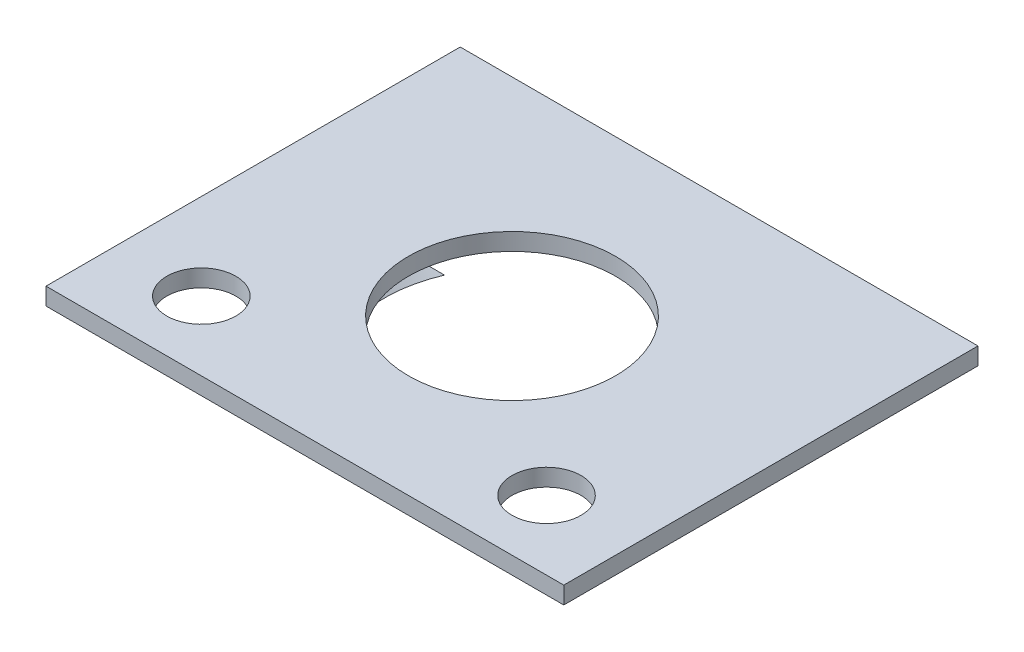
from build123d import *

# Parameters (mm, degrees)
SKETCH1_W                     = 38.1
SKETCH1_H                     = 30.48
SKETCH1_R                     = 7.62
SKETCH1_R_2                   = 2.54
BOSS_EXTRUDE1_DEPTH           = 1.27
BOSS_EXTRUDE2_DEPTH           = 1.524
BOSS_EXTRUDE3_DEPTH           = 0.762
BOSS_EXTRUDE3_DRAFT           = -45
BOSS_EXTRUDE3_PROFILE_2_DEPTH = 0.762
BOSS_EXTRUDE3_PROFILE_2_DRAFT = -45
BOSS_EXTRUDE3_PROFILE_3_DEPTH = 0.762
BOSS_EXTRUDE3_PROFILE_3_DRAFT = -45
SKETCH6_W                     = 5.08
SKETCH6_H                     = 1.016
BOSS_EXTRUDE4_DEPTH           = 0.254


with BuildPart() as part:
    # Sketch1 → Boss-Extrude1 (new body)
    with BuildSketch(Plane(origin=(0, 0, 0), x_dir=(1, 0, 0), z_dir=(0, 1, 0))):
        Rectangle(SKETCH1_W, SKETCH1_H)
        with Locations(Location((0, 0, 0), (0, 0, 270))):
            Circle(SKETCH1_R, mode=Mode.SUBTRACT)
        with Locations(Location((12.7, -10.16, 0), (0, 0, 270))):
            Circle(SKETCH1_R_2, mode=Mode.SUBTRACT)
        with Locations(Location((-12.7, -10.16, 0), (0, 0, 270))):
            Circle(SKETCH1_R_2, mode=Mode.SUBTRACT)
    extrude(amount=BOSS_EXTRUDE1_DEPTH)

    # Sketch2 → Boss-Extrude2 (add)
    with BuildSketch(Plane(origin=(0, 0, 0), x_dir=(-1, 0, 0), z_dir=(0, -1, 0))):
        with BuildLine():
            ThreePointArc((-9.731051279, 2.921), (-10.16, 0), (-9.731051279, -2.921))
            Line((-9.731051279, -2.921), (-12.271051279, -2.921))
            Line((-12.271051279, -2.921), (-12.271051279, 2.921))
            Line((-12.271051279, 2.921), (-9.731051279, 2.921))
        make_face()
        with BuildLine():
            ThreePointArc((-3.81, -9.418572079), (0, -10.16), (3.81, -9.418572079))
            Line((3.81, -9.418572079), (3.81, -11.958572079))
            Line((3.81, -11.958572079), (-3.81, -11.958572079))
            Line((-3.81, -11.958572079), (-3.81, -9.418572079))
        make_face()
        with BuildLine():
            ThreePointArc((9.731051279, -2.921), (10.16, 0), (9.731051279, 2.921))
            Line((9.731051279, 2.921), (12.271051279, 2.921))
            Line((12.271051279, 2.921), (12.271051279, -2.921))
            Line((12.271051279, -2.921), (9.731051279, -2.921))
        make_face()
    extrude(amount=BOSS_EXTRUDE2_DEPTH)


with BuildPart() as boss_extrude3_tool:
    # Sketch4 → Boss-Extrude3 (with draft: the straight prism first)
    with BuildSketch(Plane(origin=(0, -1.524, 0), x_dir=(-1, 0, 0), z_dir=(0, -1, 0))):
        with BuildLine():
            ThreePointArc((3.81, -9.418572079), (0, -10.16), (-3.81, -9.418572079))
            Line((-3.81, -9.418572079), (-3.81, -11.958572079))
            Line((-3.81, -11.958572079), (3.81, -11.958572079))
            Line((3.81, -11.958572079), (3.81, -9.418572079))
        make_face()
    extrude(amount=BOSS_EXTRUDE3_DEPTH)
    # Boss-Extrude3: the draft: its side faces are tilted about the plane it starts from
    boss_extrude3_sides = [boss_extrude3_tool.faces().sort_by_distance(p)[0] for p in [
        (3.81, -1.905, 10.688572079),
        (0, -1.905, 11.958572079),
        (-3.81, -1.905, 10.688572079),
        (0, -1.905, 10.16),
    ]]
    draft(boss_extrude3_sides, Plane(origin=(0, -1.524, 0), x_dir=(-1, 0, 0), z_dir=(0, -1, 0)), BOSS_EXTRUDE3_DRAFT)


with BuildPart() as part_1:
    add(part.part)

    # Boss-Extrude3: add boss_extrude3_tool
    add(boss_extrude3_tool.part)


with BuildPart() as boss_extrude3_profile_2_tool:
    # Sketch4 → Boss-Extrude3 profile 2 (with draft: the straight prism first)
    with BuildSketch(Plane(origin=(0, -1.524, 0), x_dir=(-1, 0, 0), z_dir=(0, -1, 0))):
        with BuildLine():
            Line((12.271051279, 2.921), (9.731051279, 2.921))
            ThreePointArc((9.731051279, 2.921), (10.16, 0), (9.731051279, -2.921))
            Line((9.731051279, -2.921), (12.271051279, -2.921))
            Line((12.271051279, -2.921), (12.271051279, 2.921))
        make_face()
    extrude(amount=BOSS_EXTRUDE3_PROFILE_2_DEPTH)
    # Boss-Extrude3 profile 2: the draft: its side faces are tilted about the plane it starts from
    boss_extrude3_profile_2_sides = [boss_extrude3_profile_2_tool.faces().sort_by_distance(p)[0] for p in [
        (-11.001051279, -1.905, -2.921),
        (-10.16, -1.905, 0),
        (-11.001051279, -1.905, 2.921),
        (-12.271051279, -1.905, 0),
    ]]
    draft(boss_extrude3_profile_2_sides, Plane(origin=(0, -1.524, 0), x_dir=(-1, 0, 0), z_dir=(0, -1, 0)), BOSS_EXTRUDE3_PROFILE_2_DRAFT)


with BuildPart() as part_2:
    add(part_1.part)

    # Boss-Extrude3 profile 2: add boss_extrude3_profile_2_tool
    add(boss_extrude3_profile_2_tool.part)


with BuildPart() as boss_extrude3_profile_3_tool:
    # Sketch4 → Boss-Extrude3 profile 3 (with draft: the straight prism first)
    with BuildSketch(Plane(origin=(0, -1.524, 0), x_dir=(-1, 0, 0), z_dir=(0, -1, 0))):
        with BuildLine():
            Line((-9.731051279, 2.921), (-12.271051279, 2.921))
            Line((-12.271051279, 2.921), (-12.271051279, -2.921))
            Line((-12.271051279, -2.921), (-9.731051279, -2.921))
            ThreePointArc((-9.731051279, -2.921), (-10.16, 0), (-9.731051279, 2.921))
        make_face()
    extrude(amount=BOSS_EXTRUDE3_PROFILE_3_DEPTH)
    # Boss-Extrude3 profile 3: the draft: its side faces are tilted about the plane it starts from
    boss_extrude3_profile_3_sides = [boss_extrude3_profile_3_tool.faces().sort_by_distance(p)[0] for p in [
        (11.001051279, -1.905, -2.921),
        (12.271051279, -1.905, 0),
        (11.001051279, -1.905, 2.921),
        (10.16, -1.905, 0),
    ]]
    draft(boss_extrude3_profile_3_sides, Plane(origin=(0, -1.524, 0), x_dir=(-1, 0, 0), z_dir=(0, -1, 0)), BOSS_EXTRUDE3_PROFILE_3_DRAFT)


with BuildPart() as part_3:
    add(part_2.part)

    # Boss-Extrude3 profile 3: add boss_extrude3_profile_3_tool
    add(boss_extrude3_profile_3_tool.part)

    # Sketch6 → Boss-Extrude4 (add)
    with BuildSketch(Plane(origin=(0, 0, 0), x_dir=(-1, 0, 0), z_dir=(0, -1, 0))):
        with Locations((0, -8.128)):
            Rectangle(SKETCH6_W, SKETCH6_H)
        with Locations((0, -9.652)):
            Rectangle(SKETCH6_W, SKETCH6_H)
    extrude(amount=BOSS_EXTRUDE4_DEPTH)


solid = part_3.part
